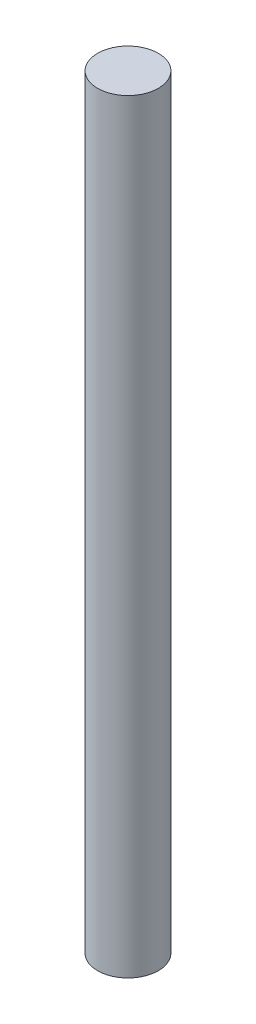
from build123d import *

# Parameters (mm, degrees)
SKETCH1_R           = 0.762
BOSS_EXTRUDE1_DEPTH = 19.177


with BuildPart() as part:
    # Sketch1 → Boss-Extrude1 (new body)
    with BuildSketch(Plane(origin=(0, 0, 0), x_dir=(1, 0, 0), z_dir=(0, 1, 0))):
        Circle(SKETCH1_R)
    extrude(amount=BOSS_EXTRUDE1_DEPTH)


solid = part.part
